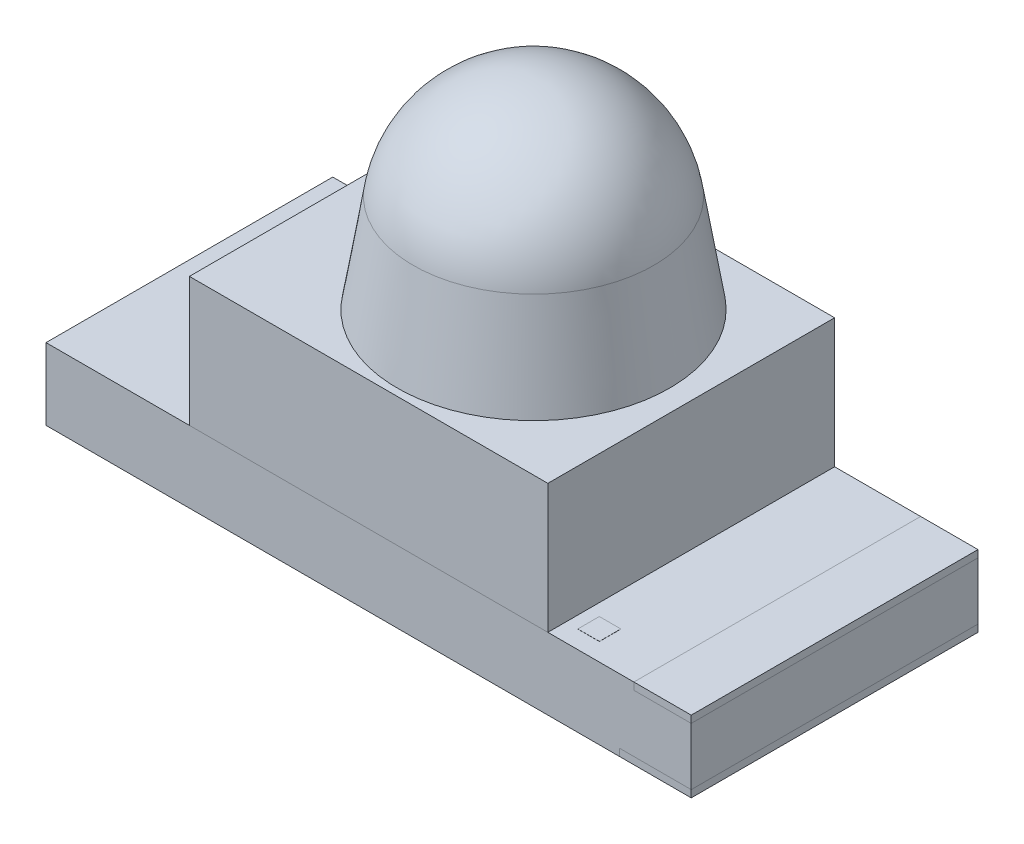
from build123d import *

# Parameters (mm, degrees)
EXTRUDE1_DEPTH      = 1
EXTRUDE2_DEPTH      = 1
SKETCH1_5_W         = 0.4
SKETCH1_5_H         = 0.05
EXTRUDE3_DEPTH      = 1
SKETCH1_5_W_2       = 0.5
EXTRUDE3_2_DEPTH    = 1
SKETCH2_W           = 0.15
SKETCH2_H           = 0.15
EXTRUDE4_DEPTH      = 0.001
EXTRUDE4_DEPTH_BACK = 0.01


with BuildPart() as part:
    # Sketch1 → Extrude1 (new body, symmetric)
    with BuildSketch(Plane.XY):
        Polygon((-1.25, 0.25), (-2.25, 0.25), (-2.25, -0.25), (1.75, -0.25), (1.75, -0.2), (2.25, -0.2), (2.25, 0.2), (1.85, 0.2), (1.85, 0.25), (1.25, 0.25), align=None)
    extrude(amount=EXTRUDE1_DEPTH, both=True)


with BuildPart() as body_2:
    # Sketch1_3 → Extrude2 (new body, symmetric)
    with BuildSketch(Plane.XY):
        Polygon((-1.25, 1.15), (-1.25, 0.25), (1.25, 0.25), (1.25, 1.15), (1.1, 1.15), (0.15, 1.15), align=None)
    extrude(amount=EXTRUDE2_DEPTH, both=True)

    # Sketch1_4 → Revolve1 (revolve)
    with BuildSketch(Plane.XY, mode=Mode.PRIVATE) as revolve1_sk:
        with BuildLine():
            Line((0.15, 2.55), (0.15, 1.15))
            Line((0.15, 1.15), (1.1, 1.15))
            Line((1.1, 1.15), (0.989096165, 1.835711557))
            ThreePointArc((0.989096165, 1.835711557), (0.700974217, 2.347246021), (0.15, 2.55))
        make_face()
    revolve(revolve1_sk.sketch.rotate(Axis((0.15, 1.15, 0), (0, 1, 0)), 180), axis=Axis((0.15, 1.15, 0), (0, 1, 0)))  # turned: the seam where the file's is


with BuildPart() as body_3:
    # Sketch1_5 → Extrude3 (new body, symmetric)
    with BuildSketch(Plane.XY):
        with Locations((2.05, 0.225)):
            Rectangle(SKETCH1_5_W, SKETCH1_5_H)
    extrude(amount=EXTRUDE3_DEPTH, both=True)


with BuildPart() as body_4:
    # Sketch1_5 → Extrude3 2 (new body, symmetric)
    with BuildSketch(Plane.XY):
        with Locations((2, -0.225)):
            Rectangle(SKETCH1_5_W_2, SKETCH1_5_H)
    extrude(amount=EXTRUDE3_2_DEPTH, both=True)


with BuildPart() as body_5:
    # Sketch2 → Extrude4 (new body, two sides)
    with BuildSketch(Plane(origin=(0, 0.25, 0), x_dir=(-1, 0, 0), z_dir=(0, 1, 0))) as extrude4_sk:
        with Locations((-1.410003, 0.800846333)):
            Rectangle(SKETCH2_W, SKETCH2_H)
    extrude(amount=EXTRUDE4_DEPTH)
    extrude(extrude4_sk.sketch, amount=-EXTRUDE4_DEPTH_BACK)


solid = Compound([part.part, body_2.part, body_3.part, body_4.part, body_5.part])
